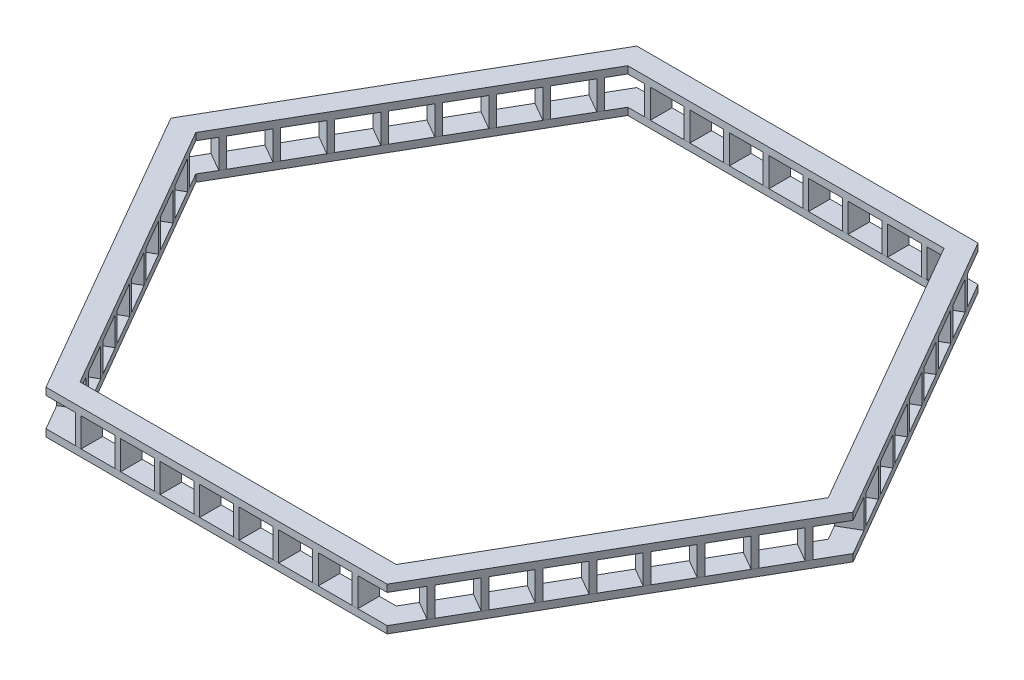
from build123d import *

# Parameters (mm, degrees)
EXTRUDE_2_DEPTH          = 50
SKETCH_2_W               = 40
SKETCH_2_H               = 150
EXTRUDE_3_DEPTH          = 200
EXTRUDE_3_2_DEPTH        = 200
EXTRUDE_3_3_DEPTH        = 200
EXTRUDE_3_4_DEPTH        = 200
EXTRUDE_3_5_DEPTH        = 200
EXTRUDE_3_6_DEPTH        = 200
EXTRUDE_3_7_DEPTH        = 200
EXTRUDE_3_8_DEPTH        = 200
PATTERN_CIRCULAR_2_COUNT = 6
EXTRUDE_5_DEPTH          = 50


with BuildPart() as part:
    # 草图1 → 凸台-拉伸2 (new body)
    with BuildSketch(Plane(origin=(0, 0, 0), x_dir=(1, 0, 0), z_dir=(0, 1, 0))):
        Polygon((-1186.602540378, -2055.255888326), (1186.602540378, -2055.255888326), (2373.205080757, 0), (1186.602540378, 2055.255888326), (-1186.602540378, 2055.255888326), (-2373.205080757, 0), align=None)
        Polygon((-1100, -1905.255888326), (1100, -1905.255888326), (2200, 0), (1100, 1905.255888326), (-1100, 1905.255888326), (-2200, 0), align=None, mode=Mode.SUBTRACT)
    extrude(amount=EXTRUDE_2_DEPTH)


with BuildPart() as body_2:
    # 草图2 → 凸台-拉伸3 (new body)
    with BuildSketch(Plane(origin=(0, 50, 0), x_dir=(1, 0, 0), z_dir=(0, 1, 0))):
        with Locations((137.5, 1980.255888326)):
            Rectangle(SKETCH_2_W, SKETCH_2_H)
    extrude(amount=EXTRUDE_3_DEPTH)


with BuildPart() as body_3:
    # 草图2 → Extrude 3 2 (new body)
    with BuildSketch(Plane(origin=(0, 50, 0), x_dir=(1, 0, 0), z_dir=(0, 1, 0))):
        with Locations((412.5, 1980.255888326)):
            Rectangle(SKETCH_2_W, SKETCH_2_H)
    extrude(amount=EXTRUDE_3_2_DEPTH)


with BuildPart() as body_4:
    # 草图2 → Extrude 3 3 (new body)
    with BuildSketch(Plane(origin=(0, 50, 0), x_dir=(1, 0, 0), z_dir=(0, 1, 0))):
        with Locations((687.5, 1980.255888326)):
            Rectangle(SKETCH_2_W, SKETCH_2_H)
    extrude(amount=EXTRUDE_3_3_DEPTH)


with BuildPart() as body_5:
    # 草图2 → Extrude 3 4 (new body)
    with BuildSketch(Plane(origin=(0, 50, 0), x_dir=(1, 0, 0), z_dir=(0, 1, 0))):
        with Locations((962.5, 1980.255888326)):
            Rectangle(SKETCH_2_W, SKETCH_2_H)
    extrude(amount=EXTRUDE_3_4_DEPTH)


with BuildPart() as body_6:
    # 草图2 → Extrude 3 5 (new body)
    with BuildSketch(Plane(origin=(0, 50, 0), x_dir=(1, 0, 0), z_dir=(0, 1, 0))):
        with Locations((-412.5, 1980.255888326)):
            Rectangle(SKETCH_2_W, SKETCH_2_H)
    extrude(amount=EXTRUDE_3_5_DEPTH)


with BuildPart() as body_7:
    # 草图2 → Extrude 3 6 (new body)
    with BuildSketch(Plane(origin=(0, 50, 0), x_dir=(1, 0, 0), z_dir=(0, 1, 0))):
        with Locations((-962.5, 1980.255888326)):
            Rectangle(SKETCH_2_W, SKETCH_2_H)
    extrude(amount=EXTRUDE_3_6_DEPTH)


with BuildPart() as body_8:
    # 草图2 → Extrude 3 7 (new body)
    with BuildSketch(Plane(origin=(0, 50, 0), x_dir=(1, 0, 0), z_dir=(0, 1, 0))):
        with Locations((-687.5, 1980.255888326)):
            Rectangle(SKETCH_2_W, SKETCH_2_H)
    extrude(amount=EXTRUDE_3_7_DEPTH)


with BuildPart() as body_9:
    # 草图2 → Extrude 3 8 (new body)
    with BuildSketch(Plane(origin=(0, 50, 0), x_dir=(1, 0, 0), z_dir=(0, 1, 0))):
        with Locations((-137.5, 1980.255888326)):
            Rectangle(SKETCH_2_W, SKETCH_2_H)
    extrude(amount=EXTRUDE_3_8_DEPTH)


with BuildPart() as pattern_circular_2_1:
    # 阵列(圆周)2: pattern copy
    add(body_5.part.rotate(Axis((0, 0, 0), (0, 1, 0)), 1 * 360 / PATTERN_CIRCULAR_2_COUNT))


with BuildPart() as pattern_circular_2_2:
    # 阵列(圆周)2: pattern copy
    add(body_5.part.rotate(Axis((0, 0, 0), (0, 1, 0)), 2 * 360 / PATTERN_CIRCULAR_2_COUNT))


with BuildPart() as pattern_circular_2_3:
    # 阵列(圆周)2: pattern copy
    add(body_5.part.rotate(Axis((0, 0, 0), (0, 1, 0)), 3 * 360 / PATTERN_CIRCULAR_2_COUNT))


with BuildPart() as pattern_circular_2_4:
    # 阵列(圆周)2: pattern copy
    add(body_5.part.rotate(Axis((0, 0, 0), (0, 1, 0)), 4 * 360 / PATTERN_CIRCULAR_2_COUNT))


with BuildPart() as pattern_circular_2_5:
    # 阵列(圆周)2: pattern copy
    add(body_5.part.rotate(Axis((0, 0, 0), (0, 1, 0)), 5 * 360 / PATTERN_CIRCULAR_2_COUNT))


with BuildPart() as pattern_circular_2_6:
    # 阵列(圆周)2: pattern copy
    add(body_3.part.rotate(Axis((0, 0, 0), (0, 1, 0)), 1 * 360 / PATTERN_CIRCULAR_2_COUNT))


with BuildPart() as pattern_circular_2_7:
    # 阵列(圆周)2: pattern copy
    add(body_3.part.rotate(Axis((0, 0, 0), (0, 1, 0)), 2 * 360 / PATTERN_CIRCULAR_2_COUNT))


with BuildPart() as pattern_circular_2_8:
    # 阵列(圆周)2: pattern copy
    add(body_3.part.rotate(Axis((0, 0, 0), (0, 1, 0)), 3 * 360 / PATTERN_CIRCULAR_2_COUNT))


with BuildPart() as pattern_circular_2_9:
    # 阵列(圆周)2: pattern copy
    add(body_3.part.rotate(Axis((0, 0, 0), (0, 1, 0)), 4 * 360 / PATTERN_CIRCULAR_2_COUNT))


with BuildPart() as pattern_circular_2_10:
    # 阵列(圆周)2: pattern copy
    add(body_3.part.rotate(Axis((0, 0, 0), (0, 1, 0)), 5 * 360 / PATTERN_CIRCULAR_2_COUNT))


with BuildPart() as pattern_circular_2_11:
    # 阵列(圆周)2: pattern copy
    add(body_7.part.rotate(Axis((0, 0, 0), (0, 1, 0)), 1 * 360 / PATTERN_CIRCULAR_2_COUNT))


with BuildPart() as pattern_circular_2_12:
    # 阵列(圆周)2: pattern copy
    add(body_7.part.rotate(Axis((0, 0, 0), (0, 1, 0)), 2 * 360 / PATTERN_CIRCULAR_2_COUNT))


with BuildPart() as pattern_circular_2_13:
    # 阵列(圆周)2: pattern copy
    add(body_7.part.rotate(Axis((0, 0, 0), (0, 1, 0)), 3 * 360 / PATTERN_CIRCULAR_2_COUNT))


with BuildPart() as pattern_circular_2_14:
    # 阵列(圆周)2: pattern copy
    add(body_7.part.rotate(Axis((0, 0, 0), (0, 1, 0)), 4 * 360 / PATTERN_CIRCULAR_2_COUNT))


with BuildPart() as pattern_circular_2_15:
    # 阵列(圆周)2: pattern copy
    add(body_7.part.rotate(Axis((0, 0, 0), (0, 1, 0)), 5 * 360 / PATTERN_CIRCULAR_2_COUNT))


with BuildPart() as pattern_circular_2_16:
    # 阵列(圆周)2: pattern copy
    add(body_8.part.rotate(Axis((0, 0, 0), (0, 1, 0)), 1 * 360 / PATTERN_CIRCULAR_2_COUNT))


with BuildPart() as pattern_circular_2_17:
    # 阵列(圆周)2: pattern copy
    add(body_8.part.rotate(Axis((0, 0, 0), (0, 1, 0)), 2 * 360 / PATTERN_CIRCULAR_2_COUNT))


with BuildPart() as pattern_circular_2_18:
    # 阵列(圆周)2: pattern copy
    add(body_8.part.rotate(Axis((0, 0, 0), (0, 1, 0)), 3 * 360 / PATTERN_CIRCULAR_2_COUNT))


with BuildPart() as pattern_circular_2_19:
    # 阵列(圆周)2: pattern copy
    add(body_8.part.rotate(Axis((0, 0, 0), (0, 1, 0)), 4 * 360 / PATTERN_CIRCULAR_2_COUNT))


with BuildPart() as pattern_circular_2_20:
    # 阵列(圆周)2: pattern copy
    add(body_8.part.rotate(Axis((0, 0, 0), (0, 1, 0)), 5 * 360 / PATTERN_CIRCULAR_2_COUNT))


with BuildPart() as pattern_circular_2_21:
    # 阵列(圆周)2: pattern copy
    add(body_6.part.rotate(Axis((0, 0, 0), (0, 1, 0)), 1 * 360 / PATTERN_CIRCULAR_2_COUNT))


with BuildPart() as pattern_circular_2_22:
    # 阵列(圆周)2: pattern copy
    add(body_6.part.rotate(Axis((0, 0, 0), (0, 1, 0)), 2 * 360 / PATTERN_CIRCULAR_2_COUNT))


with BuildPart() as pattern_circular_2_23:
    # 阵列(圆周)2: pattern copy
    add(body_6.part.rotate(Axis((0, 0, 0), (0, 1, 0)), 3 * 360 / PATTERN_CIRCULAR_2_COUNT))


with BuildPart() as pattern_circular_2_24:
    # 阵列(圆周)2: pattern copy
    add(body_6.part.rotate(Axis((0, 0, 0), (0, 1, 0)), 4 * 360 / PATTERN_CIRCULAR_2_COUNT))


with BuildPart() as pattern_circular_2_25:
    # 阵列(圆周)2: pattern copy
    add(body_6.part.rotate(Axis((0, 0, 0), (0, 1, 0)), 5 * 360 / PATTERN_CIRCULAR_2_COUNT))


with BuildPart() as pattern_circular_2_26:
    # 阵列(圆周)2: pattern copy
    add(body_9.part.rotate(Axis((0, 0, 0), (0, 1, 0)), 1 * 360 / PATTERN_CIRCULAR_2_COUNT))


with BuildPart() as pattern_circular_2_27:
    # 阵列(圆周)2: pattern copy
    add(body_9.part.rotate(Axis((0, 0, 0), (0, 1, 0)), 2 * 360 / PATTERN_CIRCULAR_2_COUNT))


with BuildPart() as pattern_circular_2_28:
    # 阵列(圆周)2: pattern copy
    add(body_9.part.rotate(Axis((0, 0, 0), (0, 1, 0)), 3 * 360 / PATTERN_CIRCULAR_2_COUNT))


with BuildPart() as pattern_circular_2_29:
    # 阵列(圆周)2: pattern copy
    add(body_9.part.rotate(Axis((0, 0, 0), (0, 1, 0)), 4 * 360 / PATTERN_CIRCULAR_2_COUNT))


with BuildPart() as pattern_circular_2_30:
    # 阵列(圆周)2: pattern copy
    add(body_9.part.rotate(Axis((0, 0, 0), (0, 1, 0)), 5 * 360 / PATTERN_CIRCULAR_2_COUNT))


with BuildPart() as pattern_circular_2_31:
    # 阵列(圆周)2: pattern copy
    add(body_2.part.rotate(Axis((0, 0, 0), (0, 1, 0)), 1 * 360 / PATTERN_CIRCULAR_2_COUNT))


with BuildPart() as pattern_circular_2_32:
    # 阵列(圆周)2: pattern copy
    add(body_2.part.rotate(Axis((0, 0, 0), (0, 1, 0)), 2 * 360 / PATTERN_CIRCULAR_2_COUNT))


with BuildPart() as pattern_circular_2_33:
    # 阵列(圆周)2: pattern copy
    add(body_2.part.rotate(Axis((0, 0, 0), (0, 1, 0)), 3 * 360 / PATTERN_CIRCULAR_2_COUNT))


with BuildPart() as pattern_circular_2_34:
    # 阵列(圆周)2: pattern copy
    add(body_2.part.rotate(Axis((0, 0, 0), (0, 1, 0)), 4 * 360 / PATTERN_CIRCULAR_2_COUNT))


with BuildPart() as pattern_circular_2_35:
    # 阵列(圆周)2: pattern copy
    add(body_2.part.rotate(Axis((0, 0, 0), (0, 1, 0)), 5 * 360 / PATTERN_CIRCULAR_2_COUNT))


with BuildPart() as pattern_circular_2_36:
    # 阵列(圆周)2: pattern copy
    add(body_4.part.rotate(Axis((0, 0, 0), (0, 1, 0)), 1 * 360 / PATTERN_CIRCULAR_2_COUNT))


with BuildPart() as pattern_circular_2_37:
    # 阵列(圆周)2: pattern copy
    add(body_4.part.rotate(Axis((0, 0, 0), (0, 1, 0)), 2 * 360 / PATTERN_CIRCULAR_2_COUNT))


with BuildPart() as pattern_circular_2_38:
    # 阵列(圆周)2: pattern copy
    add(body_4.part.rotate(Axis((0, 0, 0), (0, 1, 0)), 3 * 360 / PATTERN_CIRCULAR_2_COUNT))


with BuildPart() as pattern_circular_2_39:
    # 阵列(圆周)2: pattern copy
    add(body_4.part.rotate(Axis((0, 0, 0), (0, 1, 0)), 4 * 360 / PATTERN_CIRCULAR_2_COUNT))


with BuildPart() as pattern_circular_2_40:
    # 阵列(圆周)2: pattern copy
    add(body_4.part.rotate(Axis((0, 0, 0), (0, 1, 0)), 5 * 360 / PATTERN_CIRCULAR_2_COUNT))


with BuildPart() as body_2_1:
    add(body_2.part)

    add(body_3.part)  # 凸台-拉伸5 merges body 3

    add(body_4.part)  # 凸台-拉伸5 merges body 4

    add(body_5.part)  # 凸台-拉伸5 merges body 5

    add(body_6.part)  # 凸台-拉伸5 merges body 6

    add(body_7.part)  # 凸台-拉伸5 merges body 7

    add(body_8.part)  # 凸台-拉伸5 merges body 8

    add(body_9.part)  # 凸台-拉伸5 merges body 9

    add(pattern_circular_2_1.part)  # 凸台-拉伸5 merges 阵列(圆周)2_1

    add(pattern_circular_2_2.part)  # 凸台-拉伸5 merges 阵列(圆周)2_2

    add(pattern_circular_2_3.part)  # 凸台-拉伸5 merges 阵列(圆周)2_3

    add(pattern_circular_2_4.part)  # 凸台-拉伸5 merges 阵列(圆周)2_4

    add(pattern_circular_2_5.part)  # 凸台-拉伸5 merges 阵列(圆周)2_5

    add(pattern_circular_2_6.part)  # 凸台-拉伸5 merges 阵列(圆周)2_6

    add(pattern_circular_2_7.part)  # 凸台-拉伸5 merges 阵列(圆周)2_7

    add(pattern_circular_2_8.part)  # 凸台-拉伸5 merges 阵列(圆周)2_8

    add(pattern_circular_2_9.part)  # 凸台-拉伸5 merges 阵列(圆周)2_9

    add(pattern_circular_2_10.part)  # 凸台-拉伸5 merges 阵列(圆周)2_10

    add(pattern_circular_2_11.part)  # 凸台-拉伸5 merges 阵列(圆周)2_11

    add(pattern_circular_2_12.part)  # 凸台-拉伸5 merges 阵列(圆周)2_12

    add(pattern_circular_2_13.part)  # 凸台-拉伸5 merges 阵列(圆周)2_13

    add(pattern_circular_2_14.part)  # 凸台-拉伸5 merges 阵列(圆周)2_14

    add(pattern_circular_2_15.part)  # 凸台-拉伸5 merges 阵列(圆周)2_15

    add(pattern_circular_2_16.part)  # 凸台-拉伸5 merges 阵列(圆周)2_16

    add(pattern_circular_2_17.part)  # 凸台-拉伸5 merges 阵列(圆周)2_17

    add(pattern_circular_2_18.part)  # 凸台-拉伸5 merges 阵列(圆周)2_18

    add(pattern_circular_2_19.part)  # 凸台-拉伸5 merges 阵列(圆周)2_19

    add(pattern_circular_2_20.part)  # 凸台-拉伸5 merges 阵列(圆周)2_20

    add(pattern_circular_2_21.part)  # 凸台-拉伸5 merges 阵列(圆周)2_21

    add(pattern_circular_2_22.part)  # 凸台-拉伸5 merges 阵列(圆周)2_22

    add(pattern_circular_2_23.part)  # 凸台-拉伸5 merges 阵列(圆周)2_23

    add(pattern_circular_2_24.part)  # 凸台-拉伸5 merges 阵列(圆周)2_24

    add(pattern_circular_2_25.part)  # 凸台-拉伸5 merges 阵列(圆周)2_25

    add(pattern_circular_2_26.part)  # 凸台-拉伸5 merges 阵列(圆周)2_26

    add(pattern_circular_2_27.part)  # 凸台-拉伸5 merges 阵列(圆周)2_27

    add(pattern_circular_2_28.part)  # 凸台-拉伸5 merges 阵列(圆周)2_28

    add(pattern_circular_2_29.part)  # 凸台-拉伸5 merges 阵列(圆周)2_29

    add(pattern_circular_2_30.part)  # 凸台-拉伸5 merges 阵列(圆周)2_30

    add(pattern_circular_2_31.part)  # 凸台-拉伸5 merges 阵列(圆周)2_31

    add(pattern_circular_2_32.part)  # 凸台-拉伸5 merges 阵列(圆周)2_32

    add(pattern_circular_2_33.part)  # 凸台-拉伸5 merges 阵列(圆周)2_33

    add(pattern_circular_2_34.part)  # 凸台-拉伸5 merges 阵列(圆周)2_34

    add(pattern_circular_2_35.part)  # 凸台-拉伸5 merges 阵列(圆周)2_35

    add(pattern_circular_2_36.part)  # 凸台-拉伸5 merges 阵列(圆周)2_36

    add(pattern_circular_2_37.part)  # 凸台-拉伸5 merges 阵列(圆周)2_37

    add(pattern_circular_2_38.part)  # 凸台-拉伸5 merges 阵列(圆周)2_38

    add(pattern_circular_2_39.part)  # 凸台-拉伸5 merges 阵列(圆周)2_39

    add(pattern_circular_2_40.part)  # 凸台-拉伸5 merges 阵列(圆周)2_40
    # 草图5 → 凸台-拉伸5 (add)
    with BuildSketch(Plane(origin=(0, 250, 0), x_dir=(1, 0, 0), z_dir=(0, 1, 0))):
        Polygon((-2373.205080757, 0), (-1186.602540378, -2055.255888326), (1186.602540378, -2055.255888326), (2373.205080757, 0), (1186.602540378, 2055.255888326), (-1186.602540378, 2055.255888326), align=None)
        Polygon((-2200, 0), (-1100, -1905.255888326), (1100, -1905.255888326), (2200, 0), (1100, 1905.255888326), (-1100, 1905.255888326), align=None, mode=Mode.SUBTRACT)
    extrude(amount=EXTRUDE_5_DEPTH)


solid = Compound([part.part, body_2_1.part])
